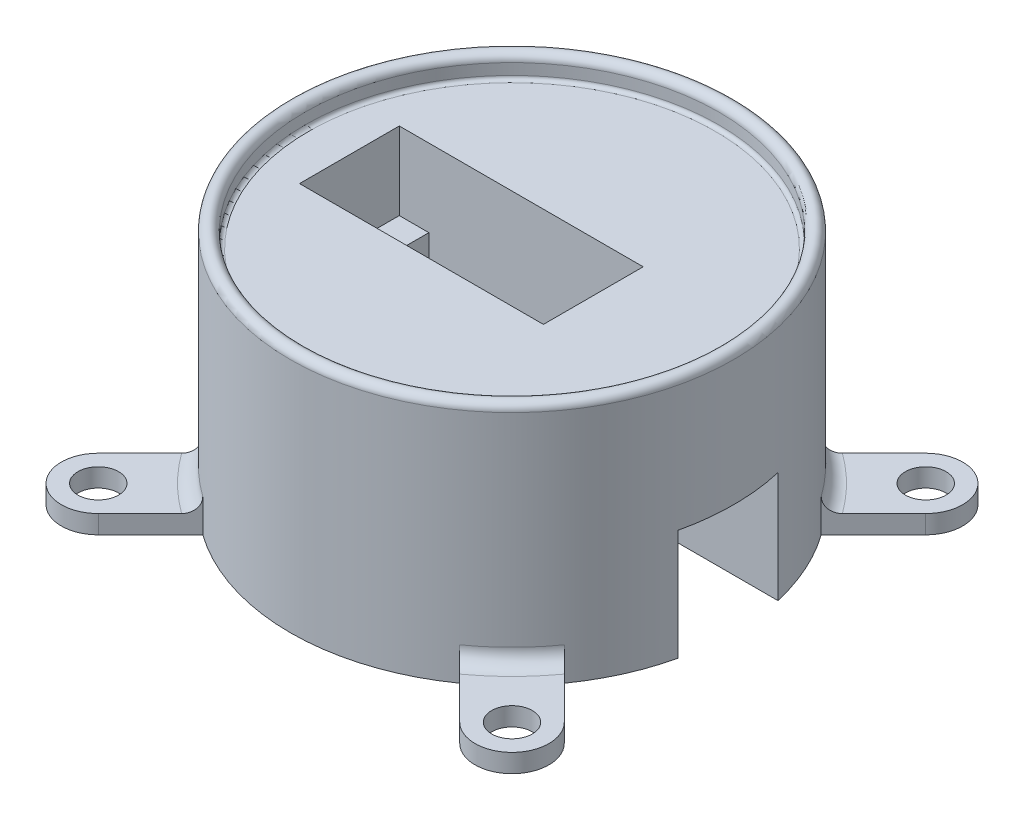
from build123d import *

# Parameters (mm, degrees)
SKETCH2_R           = 30
BOSS_EXTRUDE1_DEPTH = 30
SKETCH3_W           = 13.5
SKETCH3_H           = 15
CUT_EXTRUDE1_DEPTH  = 31
SKETCH4_W           = 33
SKETCH4_H           = 13.5
CUT_EXTRUDE2_DEPTH  = 10.5
SKETCH5_W           = 25
SKETCH5_H           = 13.5
CUT_EXTRUDE3_DEPTH  = 20.5
FILLET1_R           = 0.5
BOSS_EXTRUDE2_DEPTH = 2.5
SKETCH9_R           = 2.75
CUT_EXTRUDE4_DEPTH  = 3.5
SKETCH10_R          = 1.5
CUT_EXTRUDE5_DEPTH  = 5
FILLET2_R           = 2


with BuildPart() as part:
    # Sketch2 → Boss-Extrude1 (new body)
    with BuildSketch(Plane(origin=(0, 0, 0), x_dir=(1, 0, 0), z_dir=(0, 1, 0))):
        Circle(SKETCH2_R)
    extrude(amount=BOSS_EXTRUDE1_DEPTH)

    # Sketch3 → Cut-Extrude1 (cut, through all)
    with BuildSketch(Plane(origin=(0, 0, 0), x_dir=(0, 0, -1), z_dir=(1, 0, 0))):
        with Locations((0, 7.5)):
            Rectangle(SKETCH3_W, SKETCH3_H)
    extrude(amount=CUT_EXTRUDE1_DEPTH, mode=Mode.SUBTRACT)

    # Sketch4 → Cut-Extrude2 (cut)
    with BuildSketch(Plane(origin=(0, 30, 0), x_dir=(1, 0, 0), z_dir=(0, 1, 0))):
        with Locations((-5.5, 0)):
            Rectangle(SKETCH4_W, SKETCH4_H)
    extrude(amount=-CUT_EXTRUDE2_DEPTH, mode=Mode.SUBTRACT)

    # Sketch5 → Cut-Extrude3 (cut, through all)
    with BuildSketch(Plane(origin=(0, 19.5, 0), x_dir=(1, 0, 0), z_dir=(0, 1, 0))):
        with Locations((-5.5, 0)):
            Rectangle(SKETCH5_W, SKETCH5_H)
    extrude(amount=-CUT_EXTRUDE3_DEPTH, mode=Mode.SUBTRACT)

    # Sketch7 → Revolve1 (revolve)
    with BuildSketch(Plane.XY):
        with BuildLine():
            Line((30, 30), (28, 30))
            Line((28, 30), (28, 32))
            ThreePointArc((28, 32), (29, 33), (30, 32))
            Line((30, 32), (30, 30))
        make_face()
    revolve(axis=Axis((0, 34.959815409, 0), (0, -1, 0)))

    # Fillet1
    fillet1_edges = [part.edges().sort_by_distance(p)[0] for p in [
        (-28, 30, 0),
    ]]
    fillet(fillet1_edges, radius=FILLET1_R)

    # Sketch8 → Boss-Extrude2 (add)
    with BuildSketch(Plane(origin=(0, 0, 0), x_dir=(1, 0, 0), z_dir=(0, 1, 0))):
        with BuildLine():
            ThreePointArc((24.452034569, -17.380966757), (21.213203436, -21.213203436), (17.380966757, -24.452034569))
            Line((17.380966757, -24.452034569), (24.452034569, -31.523102381))
            ThreePointArc((24.452034569, -31.523102381), (31.523102381, -31.523102381), (31.523102381, -24.452034569))
            Line((31.523102381, -24.452034569), (24.452034569, -17.380966757))
        make_face()
        with BuildLine():
            ThreePointArc((-17.380966757, -24.452034569), (-21.213203436, -21.213203436), (-24.452034569, -17.380966757))
            Line((-24.452034569, -17.380966757), (-31.523102381, -24.452034569))
            ThreePointArc((-31.523102381, -24.452034569), (-31.523102381, -31.523102381), (-24.452034569, -31.523102381))
            Line((-24.452034569, -31.523102381), (-17.380966757, -24.452034569))
        make_face()
        with BuildLine():
            ThreePointArc((17.380966757, 24.452034569), (21.213203436, 21.213203436), (24.452034569, 17.380966757))
            Line((24.452034569, 17.380966757), (31.523102381, 24.452034569))
            ThreePointArc((31.523102381, 24.452034569), (31.523102381, 31.523102381), (24.452034569, 31.523102381))
            Line((24.452034569, 31.523102381), (17.380966757, 24.452034569))
        make_face()
        with BuildLine():
            ThreePointArc((-24.452034569, 17.380966757), (-21.213203436, 21.213203436), (-17.380966757, 24.452034569))
            Line((-17.380966757, 24.452034569), (-24.452034569, 31.523102381))
            ThreePointArc((-24.452034569, 31.523102381), (-31.523102381, 31.523102381), (-31.523102381, 24.452034569))
            Line((-31.523102381, 24.452034569), (-24.452034569, 17.380966757))
        make_face()
    extrude(amount=BOSS_EXTRUDE2_DEPTH)

    # Sketch9 → Cut-Extrude4 (cut, through all)
    with BuildSketch(Plane(origin=(0, 2.5, 0), x_dir=(1, 0, 0), z_dir=(0, 1, 0))):
        with Locations((-27.987568475, 27.987568475)):
            Circle(SKETCH9_R)
        with Locations((27.987568475, 27.987568475)):
            Circle(SKETCH9_R)
        with Locations((27.987568475, -27.987568475)):
            Circle(SKETCH9_R)
        with Locations((-27.987568475, -27.987568475)):
            Circle(SKETCH9_R)
    extrude(amount=-CUT_EXTRUDE4_DEPTH, mode=Mode.SUBTRACT)

    # Sketch10 → Cut-Extrude5 (cut)
    with BuildSketch(Plane(origin=(0, 19.5, 0), x_dir=(1, 0, 0), z_dir=(0, 1, 0))):
        with Locations((-20, 0)):
            Circle(SKETCH10_R)
        with Locations((9, 0)):
            Circle(SKETCH10_R)
    extrude(amount=-CUT_EXTRUDE5_DEPTH, mode=Mode.SUBTRACT)

    # Fillet2
    fillet2_edges = [part.edges().sort_by_distance(p)[0] for p in [
        (-21.213203436, 2.5, -21.213203436),
        (21.213203436, 2.5, 21.213203436),
        (-21.213203436, 2.5, 21.213203436),
        (21.213203436, 2.5, -21.213203436),
    ]]
    fillet(fillet2_edges, radius=FILLET2_R)


solid = part.part
